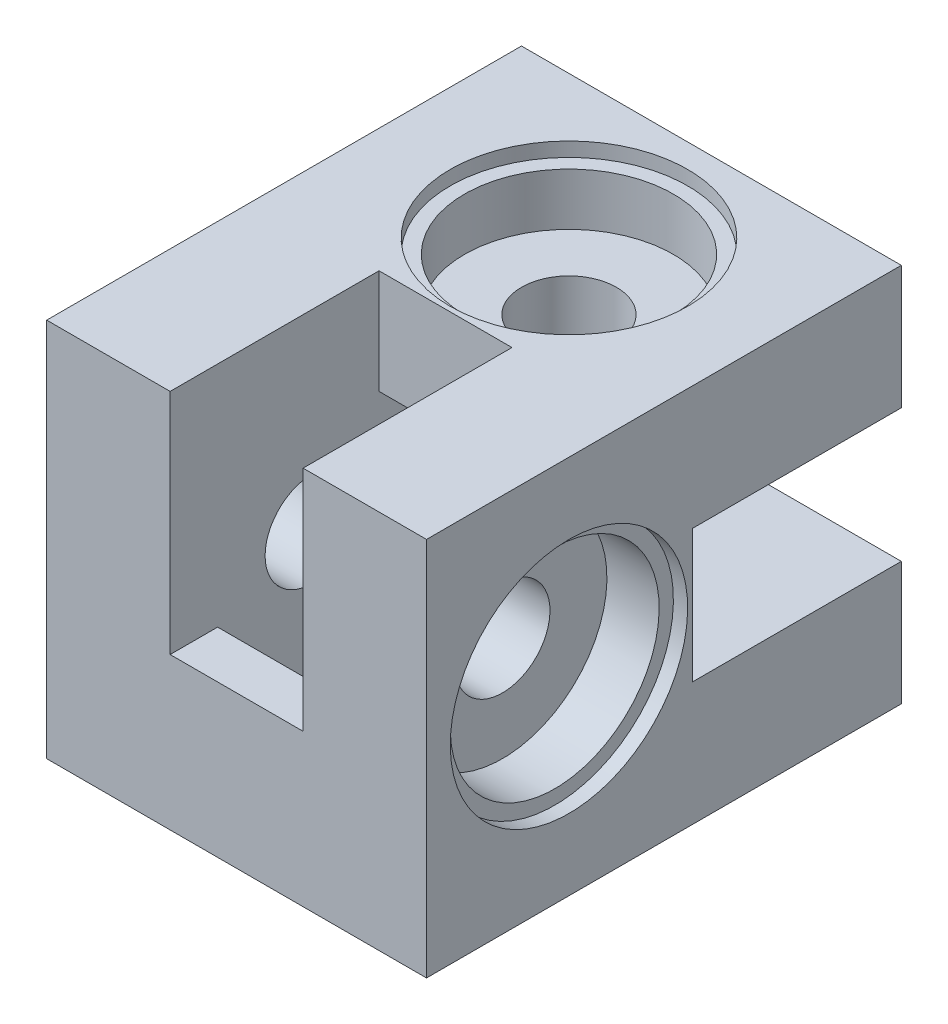
from build123d import *

# Parameters (mm, degrees)
ESQUISSE1_W              = 40
ESQUISSE1_H              = 40
BOSS_EXTRU_1_DEPTH       = 50
ESQUISSE2_R              = 5
ENL_V_MAT_EXTRU_1_DEPTH  = 41
ESQUISSE3_R              = 5
ENL_V_MAT_EXTRU_2_DEPTH  = 41
ESQUISSE4_W              = 20
ESQUISSE4_H              = 14
ENL_V_MAT_EXTRU_3_DEPTH  = 29
ESQUISSE5_W              = 14
ESQUISSE5_H              = 20
ENL_V_MAT_EXTRU_4_DEPTH  = 29
ESQUISSE6_W              = 22
ESQUISSE6_H              = 14
ENL_V_MAT_EXTRU_5_DEPTH  = 24
ESQUISSE7_W              = 14
ESQUISSE7_H              = 22
ENL_V_MAT_EXTRU_6_DEPTH  = 24
ESQUISSE8_R              = 11
ENL_V_MAT_EXTRU_7_DEPTH  = 7
ESQUISSE9_R              = 12.5
ENL_V_MAT_EXTRU_8_DEPTH  = 1.5
ESQUISSE10_R             = 11
ENL_V_MAT_EXTRU_9_DEPTH  = 7
ESQUISSE11_R             = 12.5
ENL_V_MAT_EXTRU_10_DEPTH = 1.5
BOSS_EXTRU_2_DEPTH       = 20


with BuildPart() as part:
    # Esquisse1 → Boss.-Extru.1 (new body)
    with BuildSketch(Plane.XY):
        with Locations((-20, 20)):
            Rectangle(ESQUISSE1_W, ESQUISSE1_H)
    extrude(amount=BOSS_EXTRU_1_DEPTH)

    # Esquisse2 → Enlèv. mat.-Extru.1 (cut, through all)
    with BuildSketch(Plane(origin=(0, 40, 0), x_dir=(1, 0, 0), z_dir=(0, 1, 0))):
        with Locations(Location((-20, -15, 0), (0, 0, 270))):  # turned: the seam where the file's is
            Circle(ESQUISSE2_R)
    extrude(amount=-ENL_V_MAT_EXTRU_1_DEPTH, mode=Mode.SUBTRACT)

    # Esquisse3 → Enlèv. mat.-Extru.2 (cut, through all)
    with BuildSketch(Plane.ZY.offset(40)):
        with Locations((35, 20)):
            Circle(ESQUISSE3_R)
    extrude(amount=-ENL_V_MAT_EXTRU_2_DEPTH, mode=Mode.SUBTRACT)

    # Esquisse4 → Enlèv. mat.-Extru.3 (cut)
    with BuildSketch(Plane.ZY.offset(40)):
        with Locations((15, 20)):
            Rectangle(ESQUISSE4_W, ESQUISSE4_H)
    extrude(amount=-ENL_V_MAT_EXTRU_3_DEPTH, mode=Mode.SUBTRACT)

    # Esquisse5 → Enlèv. mat.-Extru.4 (cut)
    with BuildSketch(Plane.XZ):
        with Locations((-20, 35)):
            Rectangle(ESQUISSE5_W, ESQUISSE5_H)
    extrude(amount=-ENL_V_MAT_EXTRU_4_DEPTH, mode=Mode.SUBTRACT)

    # Esquisse6 → Enlèv. mat.-Extru.5 (cut)
    with BuildSketch(Plane(origin=(0, 0, 0), x_dir=(0, 0, -1), z_dir=(1, 0, 0))):
        with Locations((-11, 20)):
            Rectangle(ESQUISSE6_W, ESQUISSE6_H)
    extrude(amount=-ENL_V_MAT_EXTRU_5_DEPTH, mode=Mode.SUBTRACT)

    # Esquisse7 → Enlèv. mat.-Extru.6 (cut)
    with BuildSketch(Plane(origin=(0, 40, 0), x_dir=(1, 0, 0), z_dir=(0, 1, 0))):
        with Locations((-20, -39)):
            Rectangle(ESQUISSE7_W, ESQUISSE7_H)
    extrude(amount=-ENL_V_MAT_EXTRU_6_DEPTH, mode=Mode.SUBTRACT)

    # Esquisse8 → Enlèv. mat.-Extru.7 (cut)
    with BuildSketch(Plane(origin=(0, 0, 0), x_dir=(0, 0, -1), z_dir=(1, 0, 0))):
        with Locations(Location((-35, 20, 0), (0, 0, 90))):  # turned: the seam where the file's is
            Circle(ESQUISSE8_R)
    extrude(amount=-ENL_V_MAT_EXTRU_7_DEPTH, mode=Mode.SUBTRACT)

    # Esquisse9 → Enlèv. mat.-Extru.8 (cut)
    with BuildSketch(Plane(origin=(0, 0, 0), x_dir=(0, 0, -1), z_dir=(1, 0, 0))):
        with Locations(Location((-35, 20, 0), (0, 0, 90))):  # turned: the seam where the file's is
            Circle(ESQUISSE9_R)
    extrude(amount=-ENL_V_MAT_EXTRU_8_DEPTH, mode=Mode.SUBTRACT)

    # Esquisse10 → Enlèv. mat.-Extru.9 (cut)
    with BuildSketch(Plane(origin=(0, 40, 0), x_dir=(1, 0, 0), z_dir=(0, 1, 0))):
        with Locations(Location((-20, -15, 0), (0, 0, 270))):  # turned: the seam where the file's is
            Circle(ESQUISSE10_R)
    extrude(amount=-ENL_V_MAT_EXTRU_9_DEPTH, mode=Mode.SUBTRACT)

    # Esquisse11 → Enlèv. mat.-Extru.10 (cut)
    with BuildSketch(Plane(origin=(0, 40, 0), x_dir=(1, 0, 0), z_dir=(0, 1, 0))):
        with Locations(Location((-20, -15, 0), (0, 0, 270))):  # turned: the seam where the file's is
            Circle(ESQUISSE11_R)
    extrude(amount=-ENL_V_MAT_EXTRU_10_DEPTH, mode=Mode.SUBTRACT)

    # Esquisse12 → Boss.-Extru.2 (add)
    with BuildSketch(Plane(origin=(0, 0, 0), x_dir=(-1, 0, 0), z_dir=(0, 0, -1))):
        Polygon((40, 12), (28, 12), (28, 0), (30, 0), (30, 10), (40, 10), align=None)
    extrude(amount=BOSS_EXTRU_2_DEPTH)


solid = part.part
